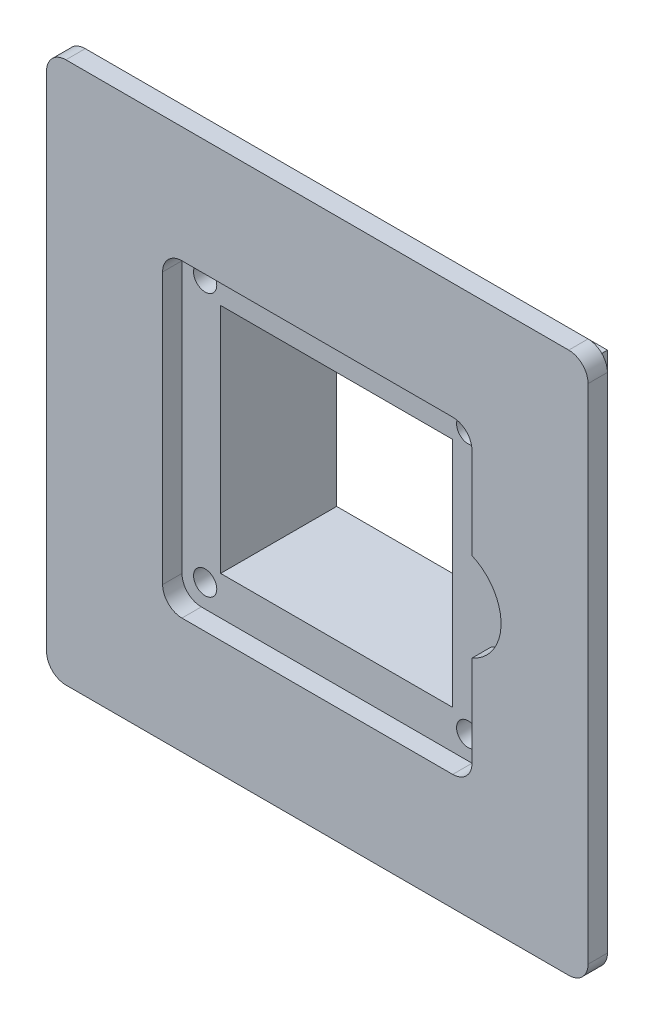
from build123d import *

# Parameters (mm, degrees)
SKETCH1_W           = 70
SKETCH1_H           = 70
BOSS_EXTRUDE1_DEPTH = 2.5
SKETCH3_W           = 50
SKETCH3_H           = 50
BOSS_EXTRUDE4_DEPTH = 10
SKETCH5_W           = 40
SKETCH5_H           = 40
BOSS_EXTRUDE5_DEPTH = 5
SKETCH2_W           = 40
SKETCH2_H           = 40
CUT_EXTRUDE4_DEPTH  = 2.5
SKETCH6_W           = 30
SKETCH6_H           = 30
CUT_EXTRUDE5_DEPTH  = 15
SKETCH8_R           = 1.5
CUT_EXTRUDE6_DEPTH  = 5
SKETCH9_R           = 1.5
CUT_EXTRUDE7_DEPTH  = 5
FILLET1_R           = 2.5
FILLET2_R           = 2.5
FILLET3_R           = 2.5
SKETCH10_R          = 6.25
CUT_EXTRUDE12_DEPTH = 2.5


with BuildPart() as part:
    # Sketch1 → Boss-Extrude1 (new body)
    with BuildSketch(Plane.XY):
        with Locations((35, 35)):
            Rectangle(SKETCH1_W, SKETCH1_H)
    extrude(amount=BOSS_EXTRUDE1_DEPTH)

    # Sketch3 → Boss-Extrude4 (add)
    with BuildSketch(Plane(origin=(0, 0, 0), x_dir=(-1, 0, 0), z_dir=(0, 0, -1))):
        with Locations((-35, 35)):
            Rectangle(SKETCH3_W, SKETCH3_H)
    extrude(amount=BOSS_EXTRUDE4_DEPTH)

    # Sketch5 → Boss-Extrude5 (add)
    with BuildSketch(Plane(origin=(0, 0, -10), x_dir=(-1, 0, 0), z_dir=(0, 0, -1))):
        with Locations((-35, 35)):
            Rectangle(SKETCH5_W, SKETCH5_H)
    extrude(amount=BOSS_EXTRUDE5_DEPTH)

    # Sketch2 → Cut-Extrude4 (cut)
    with BuildSketch(Plane.XY.offset(2.5)):
        with Locations((35, 35)):
            Rectangle(SKETCH2_W, SKETCH2_H)
    extrude(amount=-CUT_EXTRUDE4_DEPTH, mode=Mode.SUBTRACT)

    # Sketch6 → Cut-Extrude5 (cut)
    with BuildSketch(Plane.XY):
        with Locations((35, 35)):
            Rectangle(SKETCH6_W, SKETCH6_H)
    extrude(amount=-CUT_EXTRUDE5_DEPTH, mode=Mode.SUBTRACT)

    # Sketch8 → Cut-Extrude6 (cut)
    with BuildSketch(Plane.XY):
        with Locations((52, 52)):
            Circle(SKETCH8_R)
        with Locations((52, 18)):
            Circle(SKETCH8_R)
        with Locations((18, 52)):
            Circle(SKETCH8_R)
        with Locations((18, 18)):
            Circle(SKETCH8_R)
    extrude(amount=-CUT_EXTRUDE6_DEPTH, mode=Mode.SUBTRACT)

    # Sketch9 → Cut-Extrude7 (cut)
    with BuildSketch(Plane(origin=(0, 0, -15), x_dir=(-1, 0, 0), z_dir=(0, 0, -1))):
        with Locations((-18, 18)):
            Circle(SKETCH9_R)
        with Locations((-52, 18)):
            Circle(SKETCH9_R)
        with Locations((-18, 52)):
            Circle(SKETCH9_R)
        with Locations((-52, 52)):
            Circle(SKETCH9_R)
    extrude(amount=-CUT_EXTRUDE7_DEPTH, mode=Mode.SUBTRACT)

    # Fillet1
    fillet1_edges = [part.edges().sort_by_distance(p)[0] for p in [
        (0, 70, 1.25),
        (70, 70, 1.25),
        (70, 0, 1.25),
        (0, 0, 1.25),
    ]]
    fillet(fillet1_edges, radius=FILLET1_R)

    # Fillet2
    fillet2_edges = [part.edges().sort_by_distance(p)[0] for p in [
        (15, 55, 1.25),
        (55, 55, 1.25),
    ]]
    fillet(fillet2_edges, radius=FILLET2_R)

    # Fillet3
    fillet3_edges = [part.edges().sort_by_distance(p)[0] for p in [
        (15, 15, 1.25),
        (55, 15, 1.25),
    ]]
    fillet(fillet3_edges, radius=FILLET3_R)

    # Sketch10 → Cut-Extrude12 (cut)
    with BuildSketch(Plane.XY.offset(2.5)):
        with Locations((52.5, 35)):
            Circle(SKETCH10_R)
    extrude(amount=-CUT_EXTRUDE12_DEPTH, mode=Mode.SUBTRACT)


solid = part.part
